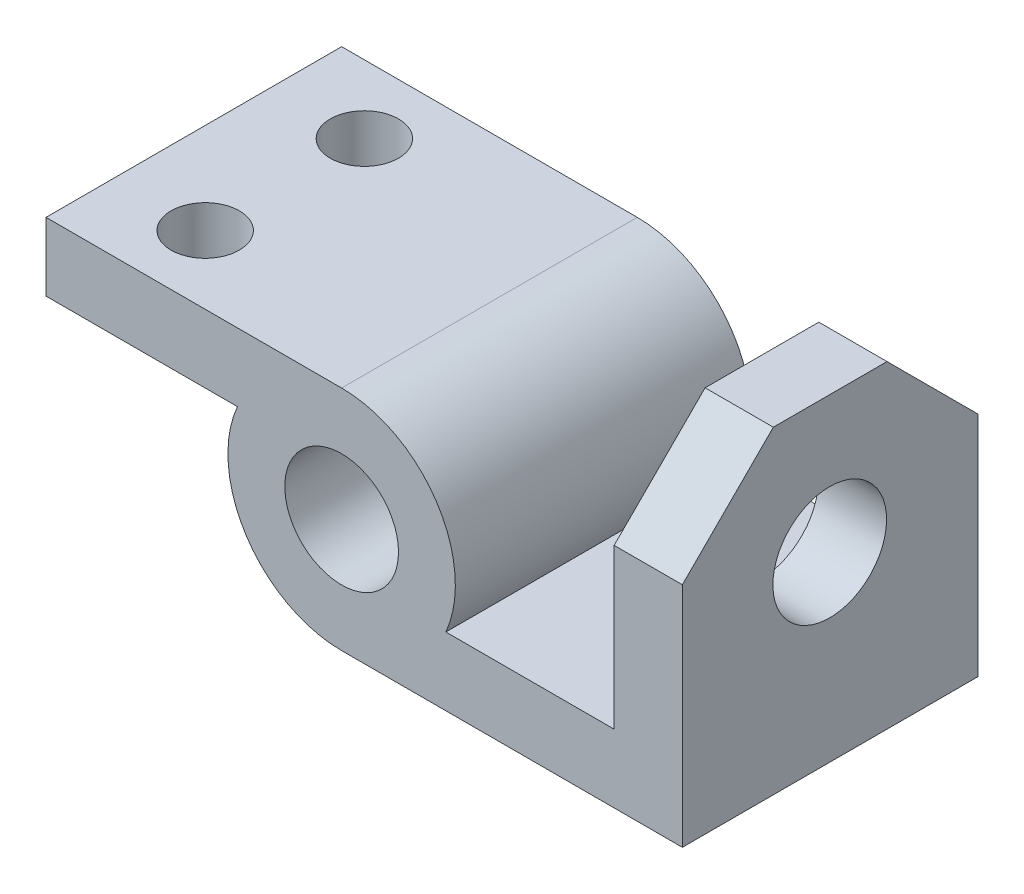
from build123d import *

# Parameters (mm, degrees)
SKETCH1_R               = 6.25
BOSS_EXTRUDE1_DEPTH     = 32.5
SKETCH2_R               = 3.75
CUT_EXTRUDE1_DEPTH      = 11.000075787
CUT_EXTRUDE1_DEPTH_BACK = 25.999924213
CUT_EXTRUDE2_REACH      = 71.956
SKETCH3_R               = 6.25
CHAMFER1_SIZE           = 10


with BuildPart() as part:
    # Sketch1 → Boss-Extrude1 (new body)
    with BuildSketch(Plane.XY):
        with BuildLine():
            Line((0, 12.5), (-32.5, 12.5))
            Line((-32.5, 12.5), (-32.5, 5))
            Line((-32.5, 5), (-11.456439237, 5))
            ThreePointArc((-11.456439237, 5), (-10.470155046, -6.828312626), (-0.043527687, -12.499924213))
            Line((-0.043527687, -12.499924213), (37.456472313, -12.499924213))
            Line((37.456472313, -12.499924213), (37.456472313, 22.500075787))
            Line((37.456472313, 22.500075787), (29.956472313, 22.500075787))
            Line((29.956472313, 22.500075787), (29.956472313, -4.999924213))
            Line((29.956472313, -4.999924213), (11.456472313, -4.999924213))
            ThreePointArc((11.456472313, -4.999924213), (10.458227686, 6.84656656), (0, 12.5))
        make_face()
        Circle(SKETCH1_R, mode=Mode.SUBTRACT)
    extrude(amount=BOSS_EXTRUDE1_DEPTH)

    # Sketch2 → Cut-Extrude1 (cut, two sides)
    with BuildSketch(Plane(origin=(0, 12.5, 0), x_dir=(1, 0, 0), z_dir=(0, 1, 0))) as cut_extrude1_sk:
        with Locations((-22.5, -7.5)):
            Circle(SKETCH2_R)
        with Locations((-22.5, -25)):
            Circle(SKETCH2_R)
    extrude(amount=CUT_EXTRUDE1_DEPTH, mode=Mode.SUBTRACT)
    extrude(cut_extrude1_sk.sketch, amount=-CUT_EXTRUDE1_DEPTH_BACK, mode=Mode.SUBTRACT)

    # Sketch3 → Cut-Extrude2 (cut, up to next)
    with BuildSketch(Plane(origin=(37.456472313, 0, 0), x_dir=(0, 0, -1), z_dir=(1, 0, 0)), mode=Mode.PRIVATE) as cut_extrude2_sk1:
        with Locations((-16.3, 7.500075787)):
            Circle(SKETCH3_R)
    cut_extrude2_tool1 = extrude(cut_extrude2_sk1.sketch, amount=-CUT_EXTRUDE2_REACH, mode=Mode.PRIVATE) & part.part
    add(cut_extrude2_tool1.solids().sort_by_distance((37.456472, 7.500076, 16.3))[0], mode=Mode.SUBTRACT)

    # Chamfer1
    chamfer1_edges = [part.edges().sort_by_distance(p)[0] for p in [
        (33.706472313, 22.500075787, 0),
        (33.706472313, 22.500075787, 32.5),
    ]]
    chamfer(chamfer1_edges, length=CHAMFER1_SIZE)


solid = part.part
